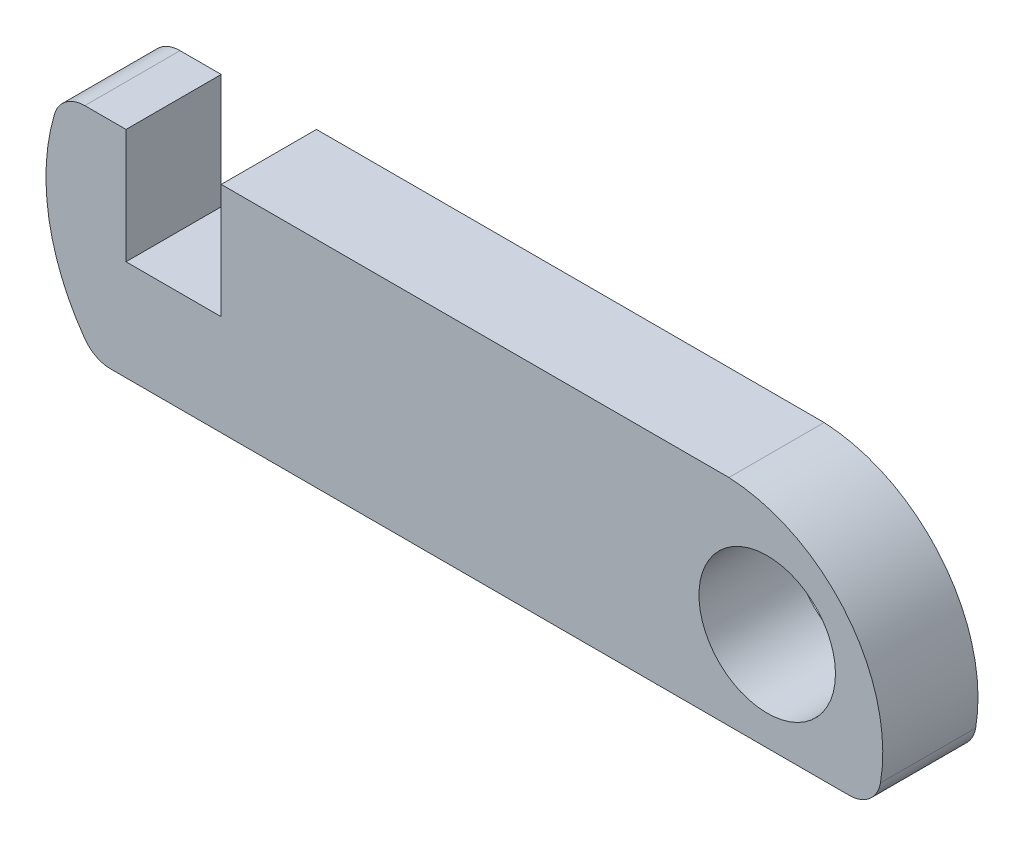
from build123d import *

# Parameters (mm, degrees)
SKETCH2_R           = 2.15
BOSS_EXTRUDE1_DEPTH = 3


with BuildPart() as part:
    # Sketch2 → Boss-Extrude1 (new body)
    with BuildSketch(Plane.XY):
        with BuildLine():
            Line((20.505045688, 0), (5, 0))
            Line((5, 0), (5, -3.611111111))
            Line((5, -3.611111111), (2, -3.611111111))
            Line((2, -3.611111111), (2, 0))
            Line((2, 0), (0.702116043, 0))
            ThreePointArc((0.702116043, 0), (0.102828022, -0.199466511), (-0.257384219, -0.718292266))
            ThreePointArc((-0.257384219, -0.718292266), (-0.42929832, -3.650374688), (0.70215346, -6.36081352))
            ThreePointArc((0.70215346, -6.36081352), (1.058001533, -6.667450679), (1.514599965, -6.777777778))
            Line((1.514599965, -6.777777778), (22.805555556, -6.777777778))
            Line((22.805555556, -6.777777778), (24.781577826, -6.777777778))
            ThreePointArc((24.781577826, -6.777777778), (25.426089078, -6.542372603), (25.767157761, -5.94698827))
            ThreePointArc((25.767157761, -5.94698827), (24.71964165, -1.898378941), (20.993425754, 0))
            Line((20.993425754, 0), (20.505045688, 0))
        make_face()
        with Locations((22.2, -3.677777778)):
            Circle(SKETCH2_R, mode=Mode.SUBTRACT)
    extrude(amount=BOSS_EXTRUDE1_DEPTH)


solid = part.part
